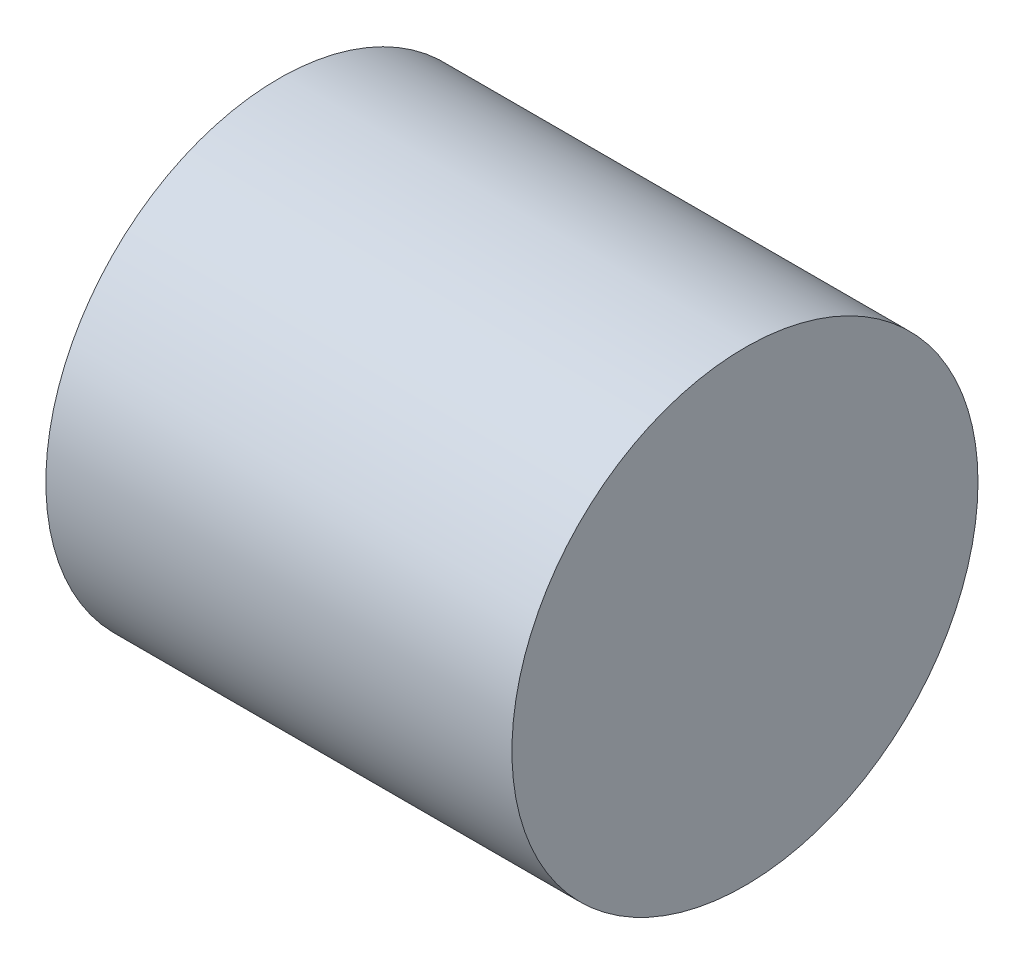
from build123d import *

# Parameters (mm, degrees)
SKETCH1_R           = 1.5875
BOSS_EXTRUDE1_DEPTH = 3.175


with BuildPart() as part:
    # Sketch1 → Boss-Extrude1 (new body)
    with BuildSketch(Plane(origin=(0, 0, 0), x_dir=(0, 0, -1), z_dir=(1, 0, 0))):
        Circle(SKETCH1_R)
    extrude(amount=BOSS_EXTRUDE1_DEPTH)


solid = part.part
